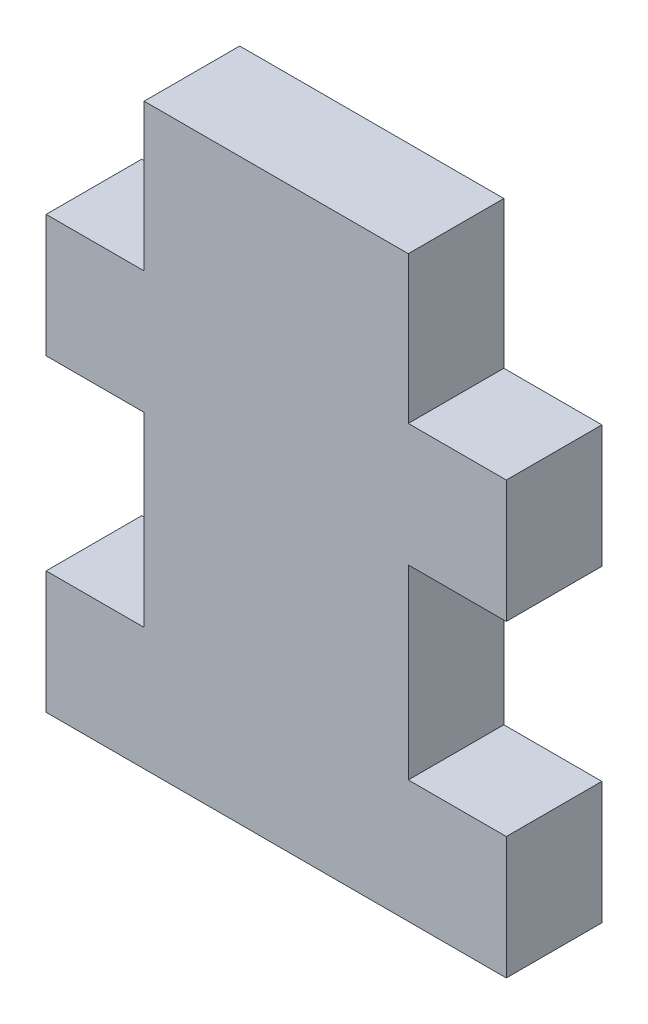
from build123d import *

# Parameters (mm, degrees)
BOSS_EXTRUDE1_DEPTH = 2.4765


with BuildPart() as part:
    # Sketch1 → Boss-Extrude1 (new, symmetric)
    with BuildSketch(Plane.XY):
        Polygon((6.8453, 60.833), (6.8453, 70.485), (11.9253, 70.485), (11.9253, 76.835), (6.8453, 76.835), (6.8453, 84.455), (-6.8453, 84.455), (-6.8453, 76.835), (-11.9253, 76.835), (-11.9253, 70.485), (-6.8453, 70.485), (-6.8453, 60.833), (-11.9253, 60.833), (-11.9253, 54.483), (11.9253, 54.483), (11.9253, 60.833), align=None)
    extrude(amount=BOSS_EXTRUDE1_DEPTH, both=True)


solid = part.part
